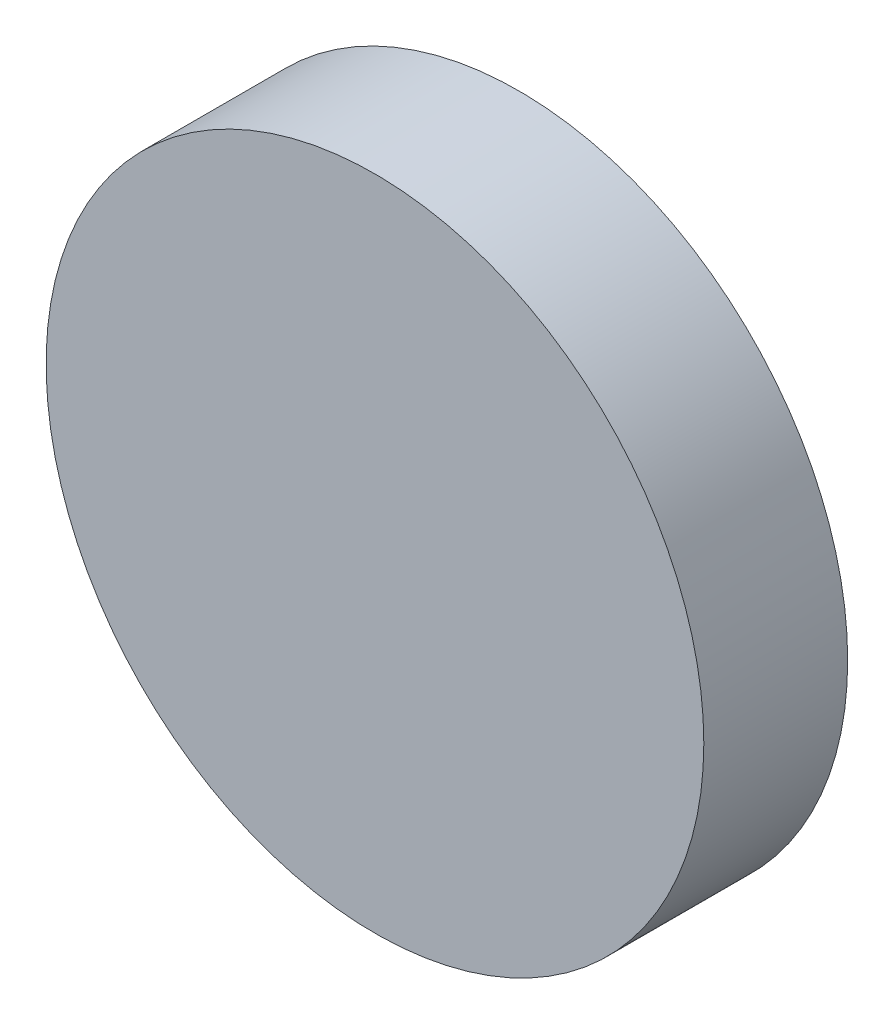
from build123d import *

# Parameters (mm, degrees)
CROQUIS2_R              = 40
CROQUIS2_R_2            = 37.5
SALIENTE_EXTRUIR1_DEPTH = 12
CROQUIS3_R              = 40
CROQUIS3_R_2            = 37.5
CROQUIS3_R_3            = 35
SALIENTE_EXTRUIR2_DEPTH = 3
CROQUIS4_R              = 40
SALIENTE_EXTRUIR3_DEPTH = 2.5


with BuildPart() as part:
    # Croquis2 → Saliente-Extruir1 (new body)
    with BuildSketch(Plane.XY.offset(34)):
        with Locations((13.541348433, 6.626768313)):
            Circle(CROQUIS2_R)
        with Locations((13.541348433, 6.626768313)):
            Circle(CROQUIS2_R_2, mode=Mode.SUBTRACT)
    extrude(amount=SALIENTE_EXTRUIR1_DEPTH)

    # Croquis3 → Saliente-Extruir2 (add)
    with BuildSketch(Plane.XY.offset(46)):
        with Locations((13.541348433, 6.626768313)):
            Circle(CROQUIS3_R)
        with Locations((13.541348433, 6.626768313)):
            Circle(CROQUIS3_R_2, mode=Mode.SUBTRACT)
        with Locations((13.541348433, 6.626768313)):
            Circle(CROQUIS3_R_3)
    extrude(amount=SALIENTE_EXTRUIR2_DEPTH)

    # Croquis4 → Saliente-Extruir3 (add)
    with BuildSketch(Plane.XY.offset(49)):
        with Locations((13.541348433, 6.626768313)):
            Circle(CROQUIS4_R)
    extrude(amount=SALIENTE_EXTRUIR3_DEPTH)


solid = part.part
